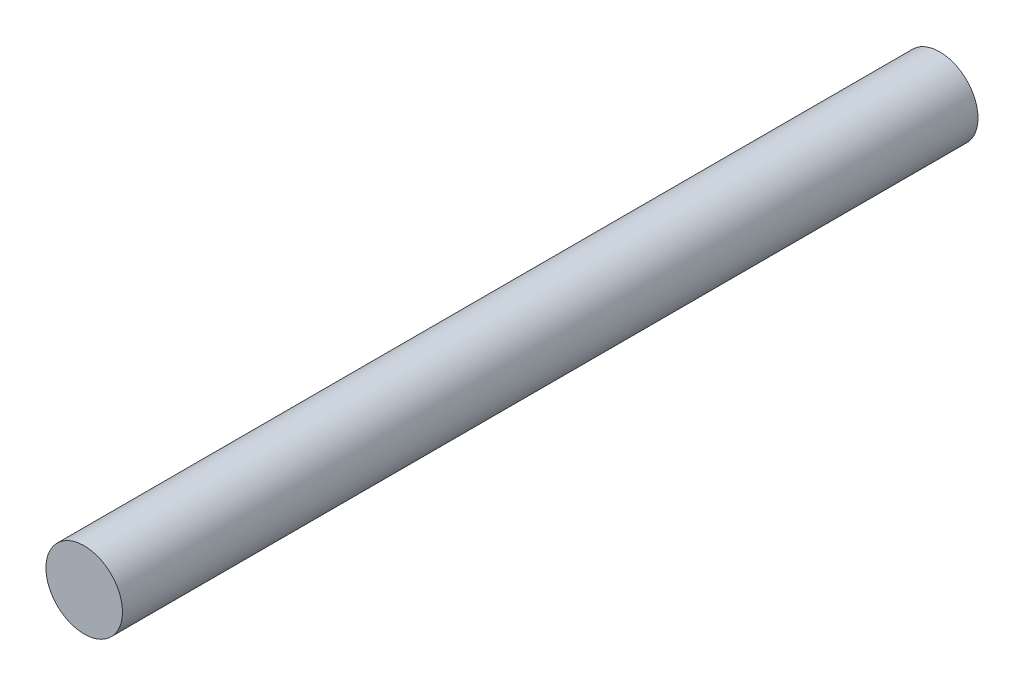
from build123d import *

# Parameters (mm, degrees)
SKETCH_1_R      = 6.260668565
EXTRUDE_1_DEPTH = 140


with BuildPart() as part:
    # 草图1 → 凸台-拉伸1 (new body)
    with BuildSketch(Plane.XY):
        Circle(SKETCH_1_R)
    extrude(amount=EXTRUDE_1_DEPTH)


solid = part.part
